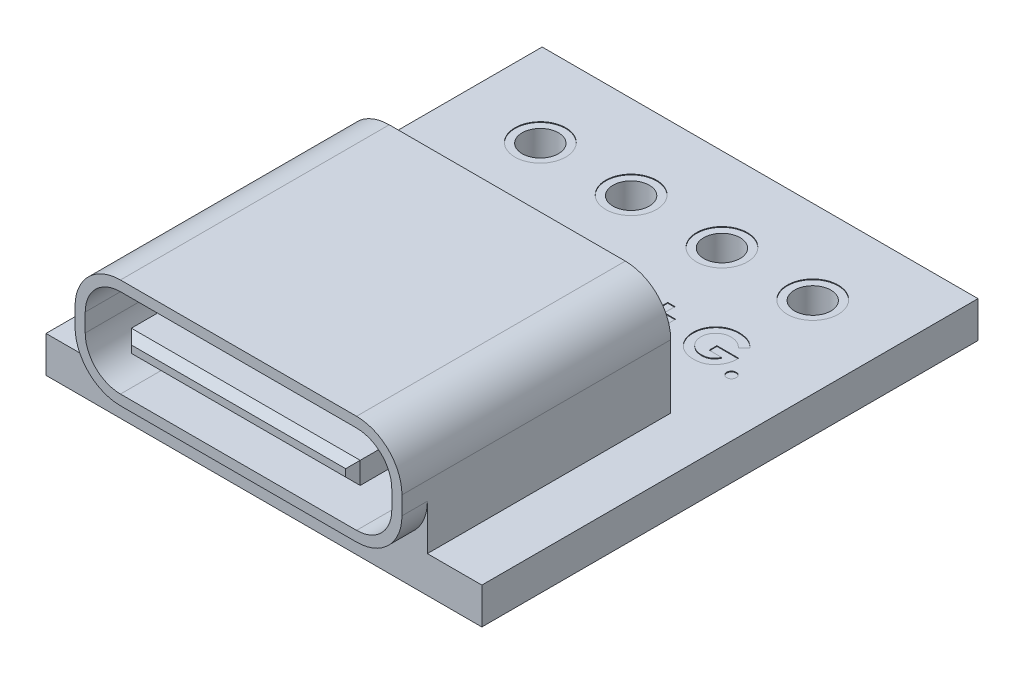
from build123d import *

# Parameters (mm, degrees)
SKETCH2_W           = 12
SKETCH2_H           = 13.66
BOSS_EXTRUDE2_DEPTH = 1
SKETCH3_W           = 9
SKETCH3_H           = 3
BOSS_EXTRUDE3_DEPTH = 7.4
FILLET1_R           = 1.25
SKETCH4_W           = 6.3
SKETCH4_H           = 0.6
CUT_EXTRUDE1_DEPTH  = 5.4
CHAMFER1_SIZE       = 0.2
SKETCH5_R           = 0.5
CUT_EXTRUDE2_DEPTH  = 2
SKETCH6_R           = 0.7
CUT_EXTRUDE3_DEPTH  = 0.02
SKETCH7_R           = 0.7
CUT_EXTRUDE4_DEPTH  = 0.02
SKETCH8_W           = 0.415384616
SKETCH8_H           = 0.2
CUT_EXTRUDE5_DEPTH  = 0.02


with BuildPart() as part:
    # Sketch2 → Boss-Extrude2 (new body)
    with BuildSketch(Plane(origin=(0, 0, 0), x_dir=(1, 0, 0), z_dir=(0, 1, 0))):
        Rectangle(SKETCH2_W, SKETCH2_H)
    extrude(amount=BOSS_EXTRUDE2_DEPTH)

    # Sketch3 → Boss-Extrude3 (add)
    with BuildSketch(Plane.XY.offset(7.53)):
        with Locations((0, 2.5)):
            Rectangle(SKETCH3_W, SKETCH3_H)
    extrude(amount=-BOSS_EXTRUDE3_DEPTH)

    # Fillet1
    fillet1_edges = [part.edges().sort_by_distance(p)[0] for p in [
        (-4.5, 1, 7.18),
        (-4.5, 4, 3.83),
        (4.5, 4, 3.83),
        (4.5, 1, 7.18),
    ]]
    fillet(fillet1_edges, radius=FILLET1_R)

    # Sketch4 → Cut-Extrude1 (cut)
    with BuildSketch(Plane.XY.offset(7.53)):
        with BuildLine():
            Line((-4.22, 2.75), (-4.22, 2.25))
            ThreePointArc((-4.22, 2.25), (-3.935893578, 1.564106422), (-3.25, 1.28))
            Line((-3.25, 1.28), (3.25, 1.28))
            ThreePointArc((3.25, 1.28), (3.935893578, 1.564106422), (4.22, 2.25))
            Line((4.22, 2.25), (4.22, 2.75))
            ThreePointArc((4.22, 2.75), (3.935893578, 3.435893578), (3.25, 3.72))
            Line((3.25, 3.72), (-3.25, 3.72))
            ThreePointArc((-3.25, 3.72), (-3.935893578, 3.435893578), (-4.22, 2.75))
        make_face()
        with Locations((0, 2.5)):
            Rectangle(SKETCH4_W, SKETCH4_H, mode=Mode.SUBTRACT)
    extrude(amount=-CUT_EXTRUDE1_DEPTH, mode=Mode.SUBTRACT)

    # Chamfer1
    chamfer1_edges = [part.edges().sort_by_distance(p)[0] for p in [
        (-3.15, 2.5, 7.53),
        (0, 2.8, 7.53),
        (3.15, 2.5, 7.53),
        (0, 2.2, 7.53),
    ]]
    chamfer(chamfer1_edges, length=CHAMFER1_SIZE)

    # Sketch5 → Cut-Extrude2 (cut, through all)
    with BuildSketch(Plane(origin=(0, 1, 0), x_dir=(1, 0, 0), z_dir=(0, 1, 0))):
        with Locations((-3.75, 4.53)):
            Circle(SKETCH5_R)
        with Locations((-1.25, 4.53)):
            Circle(SKETCH5_R)
        with Locations((1.25, 4.53)):
            Circle(SKETCH5_R)
        with Locations((3.75, 4.53)):
            Circle(SKETCH5_R)
    extrude(amount=-CUT_EXTRUDE2_DEPTH, mode=Mode.SUBTRACT)

    # Sketch6 → Cut-Extrude3 (cut)
    with BuildSketch(Plane(origin=(0, 1, 0), x_dir=(1, 0, 0), z_dir=(0, 1, 0))):
        with Locations((-3.75, 4.53)):
            Circle(SKETCH6_R)
        with Locations((-1.25, 4.53)):
            Circle(SKETCH6_R)
        with Locations((1.25, 4.53)):
            Circle(SKETCH6_R)
        with Locations((3.75, 4.53)):
            Circle(SKETCH6_R)
    extrude(amount=-CUT_EXTRUDE3_DEPTH, mode=Mode.SUBTRACT)

    # Sketch7 → Cut-Extrude4 (cut)
    with BuildSketch(Plane.XZ):
        with Locations((-3.75, -4.53)):
            Circle(SKETCH7_R)
        with Locations((-1.25, -4.53)):
            Circle(SKETCH7_R)
        with Locations((1.25, -4.53)):
            Circle(SKETCH7_R)
        with Locations((3.75, -4.53)):
            Circle(SKETCH7_R)
    extrude(amount=-CUT_EXTRUDE4_DEPTH, mode=Mode.SUBTRACT)

    # Sketch8 → Cut-Extrude5 (cut)
    with BuildSketch(Plane(origin=(0, 1, 0), x_dir=(1, 0, 0), z_dir=(0, 1, 0))):
        Polygon((-4.288461538, 2.7), (-4.058413462, 2.7), (-3.75, 1.847596154), (-3.440865385, 2.7), (-3.211538462, 2.7), (-3.646634615, 1.5), (-3.854086538, 1.5), align=None)
        with BuildLine():
            Line((-2.003846154, 2.7), (-1.732451923, 2.7))
            add(Edge.make_bspline(
                [(-1.732451923, 2.7), (-1.711293621, 2.699852096), (-1.670394384, 2.699566197), (-1.611139482, 2.696344795), (-1.556039962, 2.691390508), (-1.505060308, 2.684574988), (-1.458305036, 2.675556189), (-1.415834436, 2.664243874), (-1.377505966, 2.651185687), (-1.342899362, 2.635820081), (-1.311306862, 2.617905311), (-1.281308774, 2.597949694), (-1.252964, 2.5752222), (-1.225874766, 2.550161286), (-1.200390663, 2.522308471), (-1.17608729, 2.492125098), (-1.153559705, 2.459173468), (-1.132126946, 2.424243655), (-1.112743868, 2.38718763), (-1.095837222, 2.348320808), (-1.081674423, 2.30789331), (-1.070166416, 2.265862052), (-1.060993205, 2.222366563), (-1.054574895, 2.177319076), (-1.050607031, 2.130761294), (-1.050204525, 2.0992068), (-1.05, 2.083173077)],
                knots=[0, 0, 0, 0, 6.3469e-05, 0.000122686, 0.000177965, 0.000229401, 0.000276922, 0.000320712, 0.000361155, 0.000398279, 0.000434119, 0.000469988, 0.000506253, 0.000542994, 0.00058059, 0.000619408, 0.000659149, 0.000700252, 0.000742293, 0.000784495, 0.000827297, 0.000870686, 0.000915145, 0.000960563, 0.001007116, 0.001055208, 0.001055208, 0.001055208, 0.001055208], degree=3))
            add(Edge.make_bspline(
                [(-1.05, 2.083173077), (-1.050535557, 2.06054845), (-1.051589831, 2.016010547), (-1.060470449, 1.950651688), (-1.074833416, 1.887998703), (-1.095029052, 1.828541688), (-1.120066234, 1.772810116), (-1.149975952, 1.72178679), (-1.18431966, 1.675745577), (-1.22269725, 1.634915726), (-1.264250834, 1.599821916), (-1.307433387, 1.569766635), (-1.352665586, 1.546065538), (-1.392521475, 1.531035499), (-1.427081502, 1.521688115), (-1.457424833, 1.516163721), (-1.49189176, 1.511097518), (-1.530803658, 1.507182466), (-1.57398983, 1.503691201), (-1.621622415, 1.501794184), (-1.673547193, 1.500218044), (-1.70961386, 1.500074586), (-1.728365385, 1.5)],
                knots=[0, 0, 0, 0, 6.785e-05, 0.000133566, 0.000197475, 0.000260417, 0.000321632, 0.000380463, 0.000437483, 0.000493601, 0.000548173, 0.000600381, 0.000651132, 0.000700959, 0.00072784, 0.000758437, 0.000793419, 0.000832336, 0.000875736, 0.000923381, 0.000975324, 0.001031576, 0.001031576, 0.001031576, 0.001031576], degree=3))
            Line((-1.728365385, 1.5), (-2.003846154, 1.5))
            Line((-2.003846154, 1.5), (-2.003846154, 2.7))
        make_face()
        with BuildLine():
            Line((-1.788461538, 2.484615385), (-1.788461538, 1.715384615))
            Line((-1.788461538, 1.715384615), (-1.675961538, 1.715384615))
            add(Edge.make_bspline(
                [(-1.675961538, 1.715384615), (-1.662575766, 1.715409144), (-1.63683047, 1.71545632), (-1.59966009, 1.717703355), (-1.565286913, 1.719958759), (-1.533805561, 1.724239592), (-1.504986922, 1.729008138), (-1.479226889, 1.735644222), (-1.455994436, 1.742614867), (-1.435573342, 1.751489362), (-1.416869284, 1.761478197), (-1.399551462, 1.773181274), (-1.382834916, 1.786177101), (-1.367032174, 1.800847902), (-1.352083427, 1.816999408), (-1.338077121, 1.834714841), (-1.324826309, 1.853940152), (-1.312671115, 1.874776987), (-1.301563633, 1.897005307), (-1.291710052, 1.920409797), (-1.283539979, 1.945185367), (-1.276749515, 1.971100087), (-1.271896958, 1.998379574), (-1.267882393, 2.026821772), (-1.265812767, 2.056539369), (-1.265528724, 2.076760215), (-1.265384615, 2.087019231)],
                knots=[0, 0, 0, 0, 4.0147e-05, 7.7216e-05, 0.000111693, 0.000143447, 0.000172495, 0.000199256, 0.000223204, 0.000245172, 0.00026593, 0.000286732, 0.000307794, 0.000329398, 0.000351341, 0.000373754, 0.000397091, 0.000421333, 0.000446059, 0.000471595, 0.00049744, 0.00052426, 0.000551889, 0.000580514, 0.0006104, 0.000641178, 0.000641178, 0.000641178, 0.000641178], degree=3))
            add(Edge.make_bspline(
                [(-1.265384615, 2.087019231), (-1.265671631, 2.102740203), (-1.26623129, 2.133394882), (-1.27162852, 2.17804409), (-1.28041418, 2.220088009), (-1.29295047, 2.259370601), (-1.308752852, 2.296002271), (-1.328533217, 2.329672673), (-1.351440294, 2.360947421), (-1.369554586, 2.379294192), (-1.378605769, 2.388461538)],
                knots=[0, 0, 0, 0, 4.7145e-05, 9.193e-05, 0.000134692, 0.00017582, 0.000215434, 0.000254107, 0.000292761, 0.000331364, 0.000331364, 0.000331364, 0.000331364], degree=3))
            add(Edge.make_bspline(
                [(-1.378605769, 2.388461538), (-1.387531093, 2.396273357), (-1.405760056, 2.412228111), (-1.437764125, 2.431345988), (-1.473030951, 2.448142916), (-1.512367334, 2.461461006), (-1.555393105, 2.47199352), (-1.602364527, 2.479257537), (-1.653030056, 2.483925318), (-1.688129955, 2.484380434), (-1.70625, 2.484615385)],
                knots=[0, 0, 0, 0, 3.5518e-05, 7.2542e-05, 0.000111361, 0.000152564, 0.000196874, 0.0002441, 0.000295026, 0.000349372, 0.000349372, 0.000349372, 0.000349372], degree=3))
            Line((-1.70625, 2.484615385), (-1.788461538, 2.484615385))
        make_face(mode=Mode.SUBTRACT)
        with Locations((-0.626923077, 1.938461538)):
            Rectangle(SKETCH8_W, SKETCH8_H)
        with BuildLine():
            Line((0.388461538, 2.7), (0.659855769, 2.7))
            add(Edge.make_bspline(
                [(0.659855769, 2.7), (0.681014071, 2.699852096), (0.721913308, 2.699566197), (0.781168211, 2.696344795), (0.83626773, 2.691390508), (0.887247384, 2.684574988), (0.934002656, 2.675556189), (0.976473256, 2.664243874), (1.014801727, 2.651185687), (1.04940833, 2.635820081), (1.081000831, 2.617905311), (1.110998918, 2.597949694), (1.139343692, 2.5752222), (1.166432927, 2.550161286), (1.191917029, 2.522308471), (1.216220402, 2.492125098), (1.238747988, 2.459173468), (1.260180746, 2.424243655), (1.279563825, 2.38718763), (1.29647047, 2.348320808), (1.310633269, 2.30789331), (1.322141277, 2.265862052), (1.331314487, 2.222366563), (1.337732797, 2.177319076), (1.341700661, 2.130761294), (1.342103167, 2.0992068), (1.342307692, 2.083173077)],
                knots=[0, 0, 0, 0, 6.3469e-05, 0.000122686, 0.000177965, 0.000229401, 0.000276922, 0.000320712, 0.000361155, 0.000398279, 0.000434119, 0.000469988, 0.000506253, 0.000542994, 0.00058059, 0.000619408, 0.000659149, 0.000700252, 0.000742293, 0.000784495, 0.000827297, 0.000870686, 0.000915145, 0.000960563, 0.001007116, 0.001055208, 0.001055208, 0.001055208, 0.001055208], degree=3))
            add(Edge.make_bspline(
                [(1.342307692, 2.083173077), (1.341772136, 2.06054845), (1.340717861, 2.016010547), (1.331837243, 1.950651688), (1.317474276, 1.887998703), (1.29727864, 1.828541688), (1.272241458, 1.772810116), (1.24233174, 1.72178679), (1.207988033, 1.675745577), (1.169610442, 1.634915726), (1.128056858, 1.599821916), (1.084874305, 1.569766635), (1.039642106, 1.546065538), (0.999786218, 1.531035499), (0.96522619, 1.521688115), (0.93488286, 1.516163721), (0.900415932, 1.511097518), (0.861504034, 1.507182466), (0.818317863, 1.503691201), (0.770685278, 1.501794184), (0.7187605, 1.500218044), (0.682693832, 1.500074586), (0.663942308, 1.5)],
                knots=[0, 0, 0, 0, 6.785e-05, 0.000133566, 0.000197475, 0.000260417, 0.000321632, 0.000380463, 0.000437483, 0.000493601, 0.000548173, 0.000600381, 0.000651132, 0.000700959, 0.00072784, 0.000758437, 0.000793419, 0.000832336, 0.000875736, 0.000923381, 0.000975324, 0.001031576, 0.001031576, 0.001031576, 0.001031576], degree=3))
            Line((0.663942308, 1.5), (0.388461538, 1.5))
            Line((0.388461538, 1.5), (0.388461538, 2.7))
        make_face()
        with BuildLine():
            Line((0.603846154, 2.484615385), (0.603846154, 1.715384615))
            Line((0.603846154, 1.715384615), (0.716346154, 1.715384615))
            add(Edge.make_bspline(
                [(0.716346154, 1.715384615), (0.729731926, 1.715409144), (0.755477222, 1.71545632), (0.792647602, 1.717703355), (0.827020779, 1.719958759), (0.858502131, 1.724239592), (0.88732077, 1.729008138), (0.913080803, 1.735644222), (0.936313257, 1.742614867), (0.956734351, 1.751489362), (0.975438409, 1.761478197), (0.99275623, 1.773181274), (1.009472777, 1.786177101), (1.025275518, 1.800847902), (1.040224265, 1.816999408), (1.054230571, 1.834714841), (1.067481383, 1.853940152), (1.079636578, 1.874776987), (1.09074406, 1.897005307), (1.100597641, 1.920409797), (1.108767714, 1.945185367), (1.115558178, 1.971100087), (1.120410734, 1.998379574), (1.1244253, 2.026821772), (1.126494925, 2.056539369), (1.126778968, 2.076760215), (1.126923077, 2.087019231)],
                knots=[0, 0, 0, 0, 4.0147e-05, 7.7216e-05, 0.000111693, 0.000143447, 0.000172495, 0.000199256, 0.000223204, 0.000245172, 0.00026593, 0.000286732, 0.000307794, 0.000329398, 0.000351341, 0.000373754, 0.000397091, 0.000421333, 0.000446059, 0.000471595, 0.00049744, 0.00052426, 0.000551889, 0.000580514, 0.0006104, 0.000641178, 0.000641178, 0.000641178, 0.000641178], degree=3))
            add(Edge.make_bspline(
                [(1.126923077, 2.087019231), (1.126636061, 2.102740203), (1.126076402, 2.133394882), (1.120679173, 2.17804409), (1.111893513, 2.220088009), (1.099357223, 2.259370601), (1.08355484, 2.296002271), (1.063774475, 2.329672673), (1.040867398, 2.360947421), (1.022753106, 2.379294192), (1.013701923, 2.388461538)],
                knots=[0, 0, 0, 0, 4.7145e-05, 9.193e-05, 0.000134692, 0.00017582, 0.000215434, 0.000254107, 0.000292761, 0.000331364, 0.000331364, 0.000331364, 0.000331364], degree=3))
            add(Edge.make_bspline(
                [(1.013701923, 2.388461538), (1.004776599, 2.396273357), (0.986547636, 2.412228111), (0.954543568, 2.431345988), (0.919276741, 2.448142916), (0.879940358, 2.461461006), (0.836914587, 2.47199352), (0.789943166, 2.479257537), (0.739277636, 2.483925318), (0.704177737, 2.484380434), (0.686057692, 2.484615385)],
                knots=[0, 0, 0, 0, 3.5518e-05, 7.2542e-05, 0.000111361, 0.000152564, 0.000196874, 0.0002441, 0.000295026, 0.000349372, 0.000349372, 0.000349372, 0.000349372], degree=3))
            Line((0.686057692, 2.484615385), (0.603846154, 2.484615385))
        make_face(mode=Mode.SUBTRACT)
        Polygon((1.819230769, 2.176923077), (1.819230769, 2.469230769), (2.019230769, 2.469230769), (2.019230769, 2.176923077), (2.326923077, 2.176923077), (2.326923077, 1.976923077), (2.019230769, 1.976923077), (2.019230769, 1.684615385), (1.819230769, 1.684615385), (1.819230769, 1.976923077), (1.511538462, 1.976923077), (1.511538462, 2.176923077), align=None)
        with BuildLine():
            Line((4.042067308, 2.509134615), (3.879086538, 2.353125))
            add(Edge.make_bspline(
                [(3.879086538, 2.353125), (3.866183067, 2.366043933), (3.840864324, 2.391393011), (3.799458689, 2.424386579), (3.756575017, 2.452437634), (3.712072161, 2.475503173), (3.665888128, 2.493394811), (3.618114059, 2.506193272), (3.568672232, 2.513784256), (3.535202322, 2.514846968), (3.518269231, 2.515384615)],
                knots=[0, 0, 0, 0, 5.4742e-05, 0.000107413, 0.000158486, 0.000208264, 0.000257503, 0.000306775, 0.000356376, 0.000407166, 0.000407166, 0.000407166, 0.000407166], degree=3))
            add(Edge.make_bspline(
                [(3.518269231, 2.515384615), (3.503588758, 2.515007889), (3.474762364, 2.514268152), (3.432404753, 2.508650646), (3.391929461, 2.499266855), (3.353145267, 2.486267179), (3.31628896, 2.469350492), (3.281146989, 2.448777883), (3.247935618, 2.42439197), (3.216916362, 2.396655026), (3.188673229, 2.366371882), (3.164015483, 2.33395821), (3.143012381, 2.300018173), (3.125722544, 2.264378129), (3.112566859, 2.227092778), (3.103175421, 2.188189187), (3.097214193, 2.147780416), (3.09651035, 2.120213134), (3.096153846, 2.10625)],
                knots=[0, 0, 0, 0, 4.4032e-05, 8.6461e-05, 0.00012792, 0.000168513, 0.000208958, 0.000249362, 0.00029047, 0.000332352, 0.000374025, 0.000414507, 0.000454334, 0.000493576, 0.000533112, 0.000572699, 0.000613494, 0.000655365, 0.000655365, 0.000655365, 0.000655365], degree=3))
            add(Edge.make_bspline(
                [(3.096153846, 2.10625), (3.096486376, 2.091803583), (3.097141506, 2.063342165), (3.103434769, 2.02157381), (3.113130623, 1.981389642), (3.127322769, 1.94308782), (3.144789002, 1.906143661), (3.166939063, 1.871272808), (3.192768251, 1.837942747), (3.222230413, 1.806733772), (3.254277637, 1.777966607), (3.288985823, 1.753151311), (3.325298935, 1.731741067), (3.363803069, 1.714784845), (3.403829907, 1.701170857), (3.445785436, 1.691571827), (3.489575182, 1.685682855), (3.519452531, 1.68497475), (3.534615385, 1.684615385)],
                knots=[0, 0, 0, 0, 4.3312e-05, 8.533e-05, 0.000126433, 0.000167118, 0.000207652, 0.000248803, 0.00029078, 0.000333976, 0.000377395, 0.000419759, 0.000461771, 0.00050363, 0.000545743, 0.000588427, 0.000632555, 0.000678029, 0.000678029, 0.000678029, 0.000678029], degree=3))
            add(Edge.make_bspline(
                [(3.534615385, 1.684615385), (3.544478259, 1.684704376), (3.563841277, 1.684879085), (3.592243524, 1.687715106), (3.619446055, 1.691769527), (3.645554217, 1.6971371), (3.670304389, 1.704733179), (3.694039253, 1.713615858), (3.716619743, 1.72409919), (3.737923432, 1.736544869), (3.758267379, 1.750494955), (3.777461161, 1.76645682), (3.79584146, 1.784070582), (3.813193504, 1.803551418), (3.829223605, 1.825073511), (3.844445327, 1.848241363), (3.858684383, 1.873284901), (3.867097866, 1.890969379), (3.871394231, 1.9)],
                knots=[0, 0, 0, 0, 2.9576e-05, 5.8064e-05, 8.5534e-05, 0.000112077, 0.000137934, 0.000163115, 0.000188064, 0.000212514, 0.000237052, 0.000261982, 0.000287314, 0.000313366, 0.000340144, 0.000367747, 0.00039649, 0.000426484, 0.000426484, 0.000426484, 0.000426484], degree=3))
            Line((3.871394231, 1.9), (3.526923077, 1.9))
            Line((3.526923077, 1.9), (3.526923077, 2.115384615))
            Line((3.526923077, 2.115384615), (4.125240385, 2.115384615))
            Line((4.125240385, 2.115384615), (4.126923077, 2.064182692))
            add(Edge.make_bspline(
                [(4.126923077, 2.064182692), (4.126706863, 2.051032739), (4.126274822, 2.024756301), (4.122326421, 1.98563516), (4.115785953, 1.94703288), (4.106844508, 1.908988231), (4.095638615, 1.871314593), (4.081347594, 1.83437272), (4.064612896, 1.797912085), (4.045862854, 1.762087618), (4.024793202, 1.727713068), (4.002108627, 1.695164907), (3.978132514, 1.664499468), (3.952343393, 1.636143999), (3.925142842, 1.6098603), (3.896477317, 1.585749488), (3.866245429, 1.563791163), (3.834607329, 1.543799827), (3.801382808, 1.5262786), (3.766754533, 1.511037457), (3.730774788, 1.498093476), (3.693350683, 1.487482228), (3.654555859, 1.479294805), (3.614389484, 1.473680679), (3.572829499, 1.469865817), (3.54464024, 1.469445011), (3.530288462, 1.469230769)],
                knots=[0, 0, 0, 0, 3.9441e-05, 7.8812e-05, 0.000117818, 0.000156826, 0.000195991, 0.000235634, 0.000275542, 0.000316295, 0.000356862, 0.000396406, 0.000435263, 0.000473554, 0.000511295, 0.00054866, 0.000585827, 0.000623309, 0.000660838, 0.000698401, 0.000736724, 0.000775456, 0.000815011, 0.000855568, 0.000897071, 0.000940117, 0.000940117, 0.000940117, 0.000940117], degree=3))
            add(Edge.make_bspline(
                [(3.530288462, 1.469230769), (3.514976087, 1.469442337), (3.484622394, 1.469861727), (3.439740391, 1.473789603), (3.396160442, 1.480272308), (3.353871679, 1.48924415), (3.312775914, 1.500410325), (3.272943758, 1.514426515), (3.234456677, 1.531099217), (3.19719942, 1.54998693), (3.161648176, 1.571407242), (3.127882622, 1.594984546), (3.096087055, 1.620870502), (3.065935791, 1.648631775), (3.038133279, 1.678950739), (3.011643429, 1.71084461), (2.987749584, 1.745483128), (2.965424378, 1.781743301), (2.945590487, 1.819609936), (2.928245464, 1.858382667), (2.913453639, 1.897837003), (2.901789927, 1.938156655), (2.892320085, 1.97906048), (2.885544235, 2.02072636), (2.881717597, 2.06314908), (2.881086756, 2.091659345), (2.880769231, 2.106009615)],
                knots=[0, 0, 0, 0, 4.5929e-05, 9.1045e-05, 0.000135036, 0.000178034, 0.000220664, 0.000262706, 0.000304592, 0.000346412, 0.000387926, 0.000429006, 0.000469852, 0.000510845, 0.000551839, 0.000593175, 0.000635121, 0.000677956, 0.000720859, 0.000763254, 0.000805316, 0.000847153, 0.00088908, 0.000931207, 0.00097369, 0.001016743, 0.001016743, 0.001016743, 0.001016743], degree=3))
            add(Edge.make_bspline(
                [(2.880769231, 2.106009615), (2.881194465, 2.12558645), (2.882034176, 2.164244895), (2.889811179, 2.22118903), (2.901934368, 2.276276799), (2.919332365, 2.329307575), (2.941658103, 2.38035441), (2.968595318, 2.429537138), (3.000729145, 2.476803482), (3.025602935, 2.506067914), (3.038221154, 2.520913462)],
                knots=[0, 0, 0, 0, 5.8703e-05, 0.000115921, 0.000172083, 0.000227728, 0.000283061, 0.000339004, 0.000395744, 0.000454163, 0.000454163, 0.000454163, 0.000454163], degree=3))
            add(Edge.make_bspline(
                [(3.038221154, 2.520913462), (3.046055683, 2.529502061), (3.061607105, 2.546550301), (3.086466025, 2.570239177), (3.111955375, 2.592507597), (3.138428185, 2.612883373), (3.165745293, 2.631812541), (3.193985323, 2.648940258), (3.223000133, 2.664811879), (3.253016005, 2.67861694), (3.283875801, 2.690994328), (3.315716194, 2.70146734), (3.348298706, 2.710743938), (3.381911857, 2.717801051), (3.416216073, 2.723677675), (3.451454857, 2.727616497), (3.487532181, 2.730503372), (3.511933069, 2.73067991), (3.524278846, 2.730769231)],
                knots=[0, 0, 0, 0, 3.4866e-05, 6.9208e-05, 0.000102948, 0.000136364, 0.000169371, 0.0002026, 0.000235406, 0.000268531, 0.000301652, 0.0003351, 0.000369044, 0.000403227, 0.000438083, 0.000473416, 0.00050957, 0.000546597, 0.000546597, 0.000546597, 0.000546597], degree=3))
            add(Edge.make_bspline(
                [(3.524278846, 2.730769231), (3.537184191, 2.730570208), (3.562861089, 2.730174226), (3.601038384, 2.72743429), (3.63868518, 2.723207213), (3.67564283, 2.716866358), (3.712035363, 2.709046763), (3.747674404, 2.699027926), (3.782792452, 2.687644723), (3.805654168, 2.678569193), (3.817067308, 2.674038462)],
                knots=[0, 0, 0, 0, 3.8714e-05, 7.7026e-05, 0.000114775, 0.000152318, 0.000189473, 0.00022639, 0.000263334, 0.000300164, 0.000300164, 0.000300164, 0.000300164], degree=3))
            add(Edge.make_bspline(
                [(3.817067308, 2.674038462), (3.826670053, 2.66985125), (3.84620177, 2.661334579), (3.874618012, 2.645752928), (3.903103682, 2.628478881), (3.931351406, 2.608880856), (3.959318143, 2.586995513), (3.987295894, 2.563168525), (4.014999052, 2.537122057), (4.032927705, 2.518584582), (4.042067308, 2.509134615)],
                knots=[0, 0, 0, 0, 3.1413e-05, 6.3894e-05, 9.7122e-05, 0.00013133, 0.00016696, 0.000203619, 0.000241543, 0.000280979, 0.000280979, 0.000280979, 0.000280979], degree=3))
        make_face()
        with BuildLine():
            add(Edge.make_bspline(
                [(4.426923077, 1.746153846), (4.435617898, 1.74567713), (4.4527365, 1.744738558), (4.477470546, 1.737734095), (4.499793165, 1.725149579), (4.519752569, 1.708735258), (4.536629738, 1.68898664), (4.548828174, 1.666465755), (4.556424446, 1.641827012), (4.55726308, 1.624654553), (4.557692308, 1.615865385)],
                knots=[0, 0, 0, 0, 2.6073e-05, 5.1332e-05, 7.6292e-05, 0.000102423, 0.000128523, 0.000153694, 0.000178791, 0.000205103, 0.000205103, 0.000205103, 0.000205103], degree=3))
            add(Edge.make_bspline(
                [(4.557692308, 1.615865385), (4.557265892, 1.607074804), (4.556432752, 1.589899587), (4.548775609, 1.565212835), (4.536647966, 1.542506849), (4.519751215, 1.52254661), (4.499875824, 1.505822947), (4.477419223, 1.493354478), (4.452783618, 1.48595267), (4.435626192, 1.485065435), (4.426923077, 1.484615385)],
                knots=[0, 0, 0, 0, 2.6312e-05, 5.1409e-05, 7.6791e-05, 0.000103075, 0.00012936, 0.000154319, 0.000179647, 0.000205719, 0.000205719, 0.000205719, 0.000205719], degree=3))
            add(Edge.make_bspline(
                [(4.426923077, 1.484615385), (4.4182179, 1.485061775), (4.401056408, 1.485941795), (4.376382509, 1.493416868), (4.353760116, 1.505739703), (4.333879731, 1.522566896), (4.316907493, 1.542436168), (4.30512465, 1.565284476), (4.297396183, 1.58989028), (4.296574433, 1.607071653), (4.296153846, 1.615865385)],
                knots=[0, 0, 0, 0, 2.6073e-05, 5.14e-05, 7.657e-05, 0.000102855, 0.000129139, 0.000154408, 0.000179505, 0.000205817, 0.000205817, 0.000205817, 0.000205817], degree=3))
            add(Edge.make_bspline(
                [(4.296153846, 1.615865385), (4.296577207, 1.624657759), (4.297404379, 1.641836482), (4.305072235, 1.666393288), (4.316926377, 1.689057705), (4.333878316, 1.708714931), (4.353843201, 1.725232173), (4.376330898, 1.73767256), (4.401103502, 1.744749513), (4.418226183, 1.74568082), (4.426923077, 1.746153846)],
                knots=[0, 0, 0, 0, 2.6312e-05, 5.1409e-05, 7.6465e-05, 0.000102566, 0.000128697, 0.000153867, 0.000179127, 0.0002052, 0.0002052, 0.0002052, 0.0002052], degree=3))
        make_face()
    extrude(amount=-CUT_EXTRUDE5_DEPTH, mode=Mode.SUBTRACT)


solid = part.part
